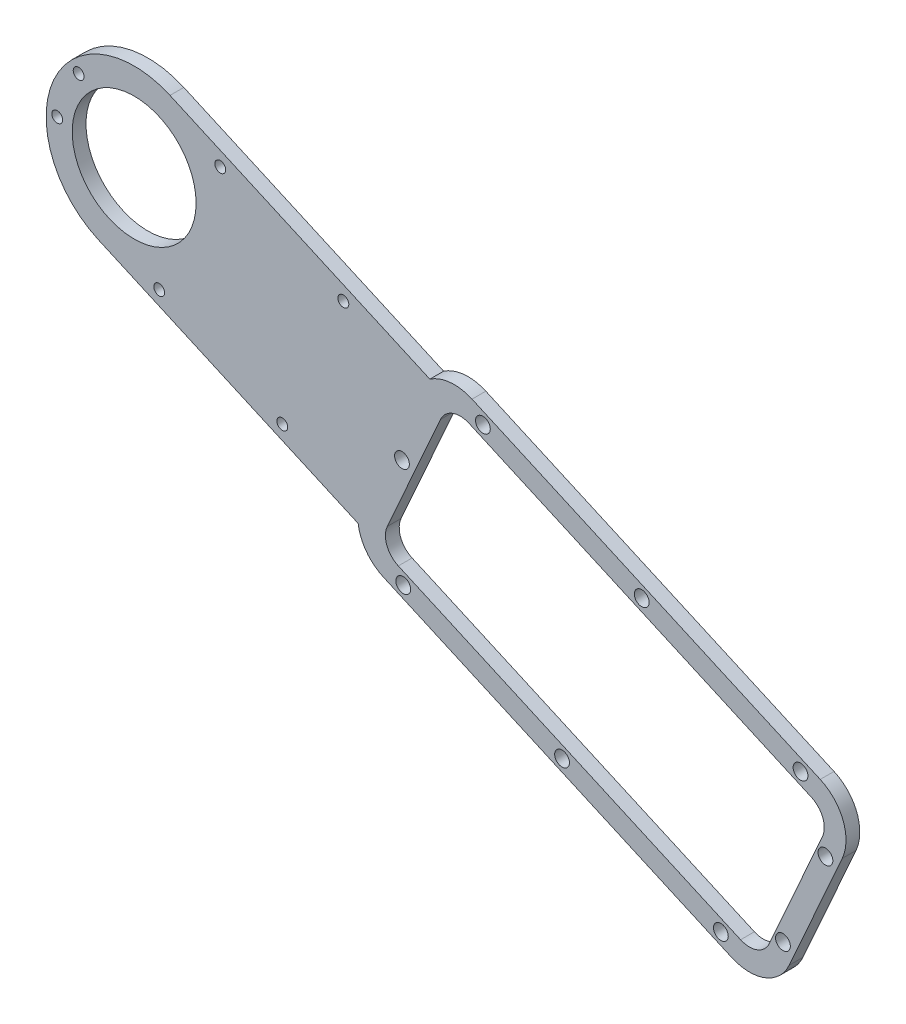
from build123d import *

# Parameters (mm, degrees)
SKETCH1_R           = 14.25
SKETCH1_R_2         = 1.7
BOSS_EXTRUDE1_DEPTH = 3.175
SKETCH5_R           = 1.25
CUT_EXTRUDE4_DEPTH  = 4.175
CUT_EXTRUDE5_DEPTH  = 10
FILLET1_R           = 5
FILLET2_R           = 5


with BuildPart() as part:
    # Sketch1 → Boss-Extrude1 (new body)
    with BuildSketch(Plane.XY):
        with BuildLine():
            Line((-72.715301765, 90.837326721), (-152.817002247, 126.544575004))
            ThreePointArc((-152.817002247, 126.544575004), (-157.784388135, 127.370762315), (-162.524605276, 125.671394934))
            Line((-162.524605276, 125.671394934), (-222.299360222, 152.317421212))
            ThreePointArc((-222.299360222, 152.317421212), (-249.039738928, 142.066706765), (-238.78902448, 115.326328059))
            Line((-238.78902448, 115.326328059), (-179.014269534, 88.680301782))
            ThreePointArc((-179.014269534, 88.680301782), (-177.109561802, 84.018800254), (-173.174612442, 80.876558766))
            Line((-173.174612442, 80.876558766), (-93.072911961, 45.169310483))
            ThreePointArc((-93.072911961, 45.169310483), (-85.421957972, 44.965480094), (-79.867786674, 50.231391692))
            Line((-79.867786674, 50.231391692), (-67.653220557, 77.632201435))
            ThreePointArc((-67.653220557, 77.632201435), (-67.449390168, 85.283155423), (-72.715301765, 90.837326721))
        make_face()
        with Locations((-230.544192351, 133.821874636)):
            Circle(SKETCH1_R, mode=Mode.SUBTRACT)
        with Locations((-95.571468701, 49.02024728)):
            Circle(SKETCH1_R_2, mode=Mode.SUBTRACT)
        with Locations((-132.105881692, 65.306335437)):
            Circle(SKETCH1_R_2, mode=Mode.SUBTRACT)
        with Locations((-168.640294682, 81.592423593)):
            Circle(SKETCH1_R_2, mode=Mode.SUBTRACT)
        with Locations((-150.318445506, 122.693638207)):
            Circle(SKETCH1_R_2, mode=Mode.SUBTRACT)
        with Locations((-113.784032516, 106.407550051)):
            Circle(SKETCH1_R_2, mode=Mode.SUBTRACT)
        with Locations((-77.249619525, 90.121461895)):
            Circle(SKETCH1_R_2, mode=Mode.SUBTRACT)
        with Locations((-81.295075004, 54.152214057)):
            Circle(SKETCH1_R_2, mode=Mode.SUBTRACT)
        with Locations((-71.52342211, 76.072861852)):
            Circle(SKETCH1_R_2, mode=Mode.SUBTRACT)
        with Locations((-168.932649456, 106.357056211)):
            Circle(SKETCH1_R_2, mode=Mode.SUBTRACT)
    extrude(amount=BOSS_EXTRUDE1_DEPTH)

    # Sketch5 → Cut-Extrude4 (cut, through all)
    with BuildSketch(Plane.XY.offset(3.175)):
        with Locations((-196.466353254, 99.744559857)):
            Circle(SKETCH5_R)
        with Locations((-224.780523322, 112.366278179)):
            Circle(SKETCH5_R)
        with Locations((-210.733772287, 143.877209383)):
            Circle(SKETCH5_R)
        with Locations((-182.419602219, 131.255491062)):
            Circle(SKETCH5_R)
        with Locations((-243.306863065, 146.157868161)):
            Circle(SKETCH5_R)
        with Locations((-248.250389122, 135.068107325)):
            Circle(SKETCH5_R)
    extrude(amount=-CUT_EXTRUDE4_DEPTH, mode=Mode.SUBTRACT)

    # Sketch6 → Cut-Extrude5 (cut)
    with BuildSketch(Plane.XY.offset(3.175)):
        Polygon((-158.059591703, 123.407293834), (-70.184261161, 84.234764078), (-86.470349317, 47.700351088), (-174.345679859, 86.872880843), align=None)
    extrude(amount=-CUT_EXTRUDE5_DEPTH, mode=Mode.SUBTRACT)

    # Fillet1
    fillet1_edges = [part.edges().sort_by_distance(p)[0] for p in [
        (-174.345679859, 86.872880843, 1.5875),
        (-158.059591703, 123.407293834, 1.5875),
    ]]
    fillet(fillet1_edges, radius=FILLET1_R)

    # Fillet2
    fillet2_edges = [part.edges().sort_by_distance(p)[0] for p in [
        (-70.184261161, 84.234764078, 1.5875),
        (-86.470349317, 47.700351088, 1.5875),
    ]]
    fillet(fillet2_edges, radius=FILLET2_R)


solid = part.part
